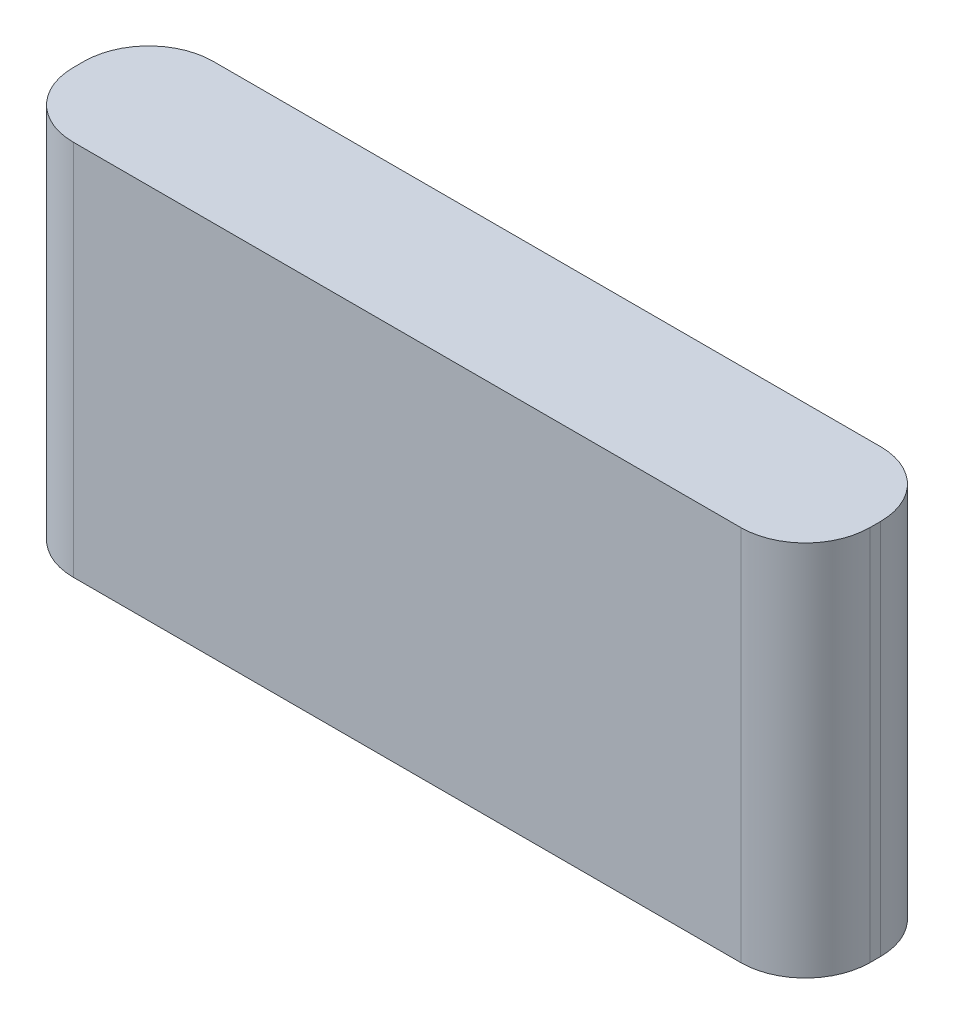
from build123d import *

# Parameters (mm, degrees)
SKETCH1_W           = 74
SKETCH1_H           = 35
BOSS_EXTRUDE1_DEPTH = 13
FILLET2_R           = 6


with BuildPart() as part:
    # Sketch1 → Boss-Extrude1 (new body)
    with BuildSketch(Plane.XY):
        Rectangle(SKETCH1_W, SKETCH1_H)
    extrude(amount=BOSS_EXTRUDE1_DEPTH)

    # Fillet2
    fillet2_edges = [part.edges().sort_by_distance(p)[0] for p in [
        (-37, 0, 13),
        (37, 0, 13),
        (-37, 0, 0),
        (37, 0, 0),
    ]]
    fillet(fillet2_edges, radius=FILLET2_R)


solid = part.part
